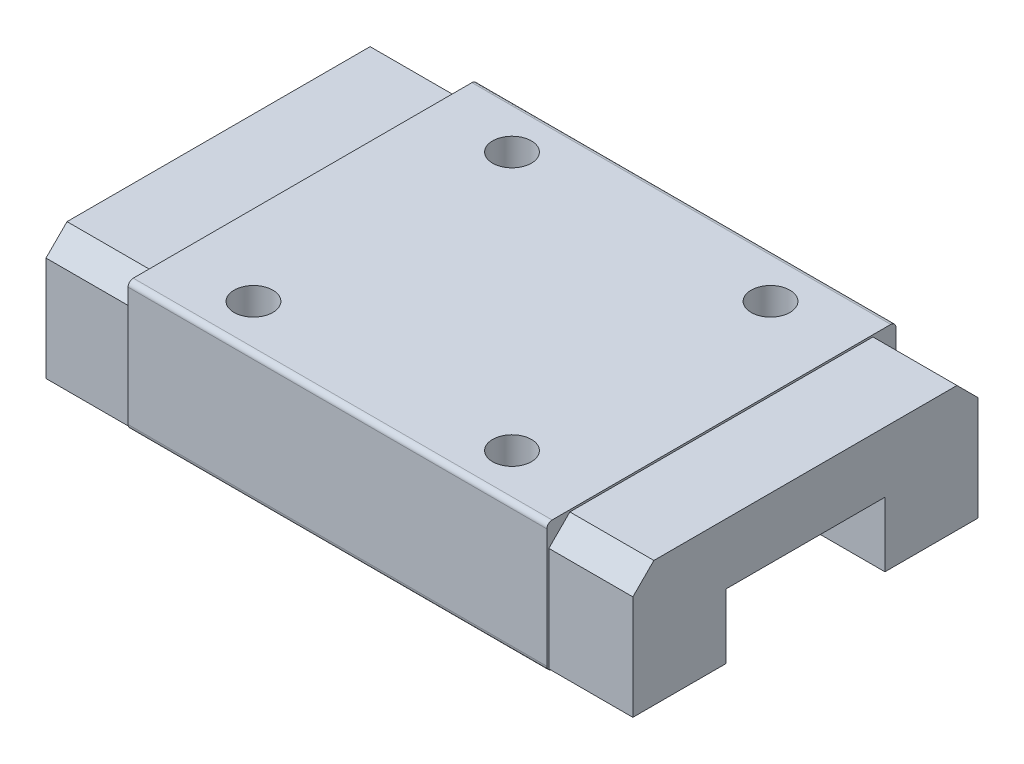
from build123d import *

# Parameters (mm, degrees)
BOSS_EXTRUDE1_DEPTH      = 16.2
BOSS_EXTRUDE1_DEPTH_BACK = 16.2
SKETCH2_R                = 1.5
CUT_EXTRUDE1_DEPTH       = 5
BOSS_EXTRUDE2_DEPTH      = 6.5
BOSS_EXTRUDE3_DEPTH      = 6.5
FILLET1_R                = 0.4


with BuildPart() as part:
    # Sketch1 → Boss-Extrude1 (new body, two sides)
    with BuildSketch(Plane(origin=(0, 0, 0), x_dir=(0, 0, -1), z_dir=(1, 0, 0))) as boss_extrude1_sk:
        Polygon((13.5, 0), (-13.5, 0), (-13.5, -10), (-6, -10), (-6, -5), (6, -5), (6, -10), (13.5, -10), align=None)
    extrude(amount=BOSS_EXTRUDE1_DEPTH)
    extrude(boss_extrude1_sk.sketch, amount=-BOSS_EXTRUDE1_DEPTH_BACK)

    # Sketch2 → Cut-Extrude1 (cut)
    with BuildSketch(Plane(origin=(0, 0, 0), x_dir=(1, 0, 0), z_dir=(0, 1, 0))):
        with Locations((-10, 10)):
            Circle(SKETCH2_R)
        with Locations((-10, -10)):
            Circle(SKETCH2_R)
        with Locations((10, -10)):
            Circle(SKETCH2_R)
        with Locations((10, 10)):
            Circle(SKETCH2_R)
    extrude(amount=-CUT_EXTRUDE1_DEPTH, mode=Mode.SUBTRACT)

    # Fillet1
    fillet1_edges = [part.edges().sort_by_distance(p)[0] for p in [
        (0, -10, 13.5),
        (0, 0, 13.5),
        (0, 0, -13.5),
        (0, -10, -13.5),
    ]]
    fillet(fillet1_edges, radius=FILLET1_R)


with BuildPart() as body_2:
    # Sketch3 → Boss-Extrude2 (new body)
    with BuildSketch(Plane.ZY.offset(16.2)):
        Polygon((-13.35, -1.776345597), (-11.723654403, -0.15), (11.723654403, -0.15), (13.35, -1.776345597), (13.35, -9.85), (6.15, -9.85), (6.15, -4.85), (-6.15, -4.85), (-6.15, -9.85), (-13.35, -9.85), align=None)
    extrude(amount=BOSS_EXTRUDE2_DEPTH)


with BuildPart() as body_3:
    # Sketch4 → Boss-Extrude3 (new body)
    with BuildSketch(Plane(origin=(16.2, 0, 0), x_dir=(0, 0, -1), z_dir=(1, 0, 0))):
        Polygon((13.35, -1.776345597), (11.723654403, -0.15), (-11.723654403, -0.15), (-13.35, -1.776345597), (-13.35, -9.85), (-6.15, -9.85), (-6.15, -4.85), (6.15, -4.85), (6.15, -9.85), (13.35, -9.85), align=None)
    extrude(amount=BOSS_EXTRUDE3_DEPTH)


solid = Compound([part.part, body_2.part, body_3.part])
